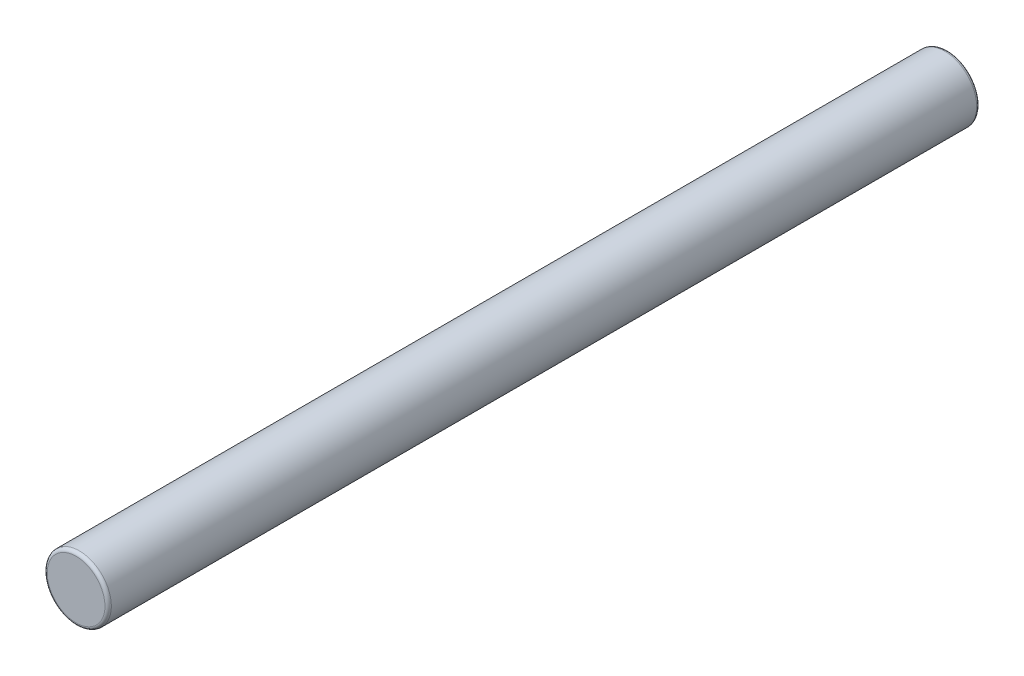
from build123d import *

# Parameters (mm, degrees)
SCHIZZO1_R                   = 2.5
ESTRUSIONE_ESTRUSIONE1_DEPTH = 68
RACCORDO1_R                  = 0.25


with BuildPart() as part:
    # Schizzo1 → Estrusione-Estrusione1 (new body)
    with BuildSketch(Plane.XY):
        Circle(SCHIZZO1_R)
    extrude(amount=ESTRUSIONE_ESTRUSIONE1_DEPTH)

    # Raccordo1
    raccordo1_edges = [part.edges().sort_by_distance(p)[0] for p in [
        (-2.5, 0, 0),
        (-2.5, 0, 68),
    ]]
    fillet(raccordo1_edges, radius=RACCORDO1_R)


solid = part.part
